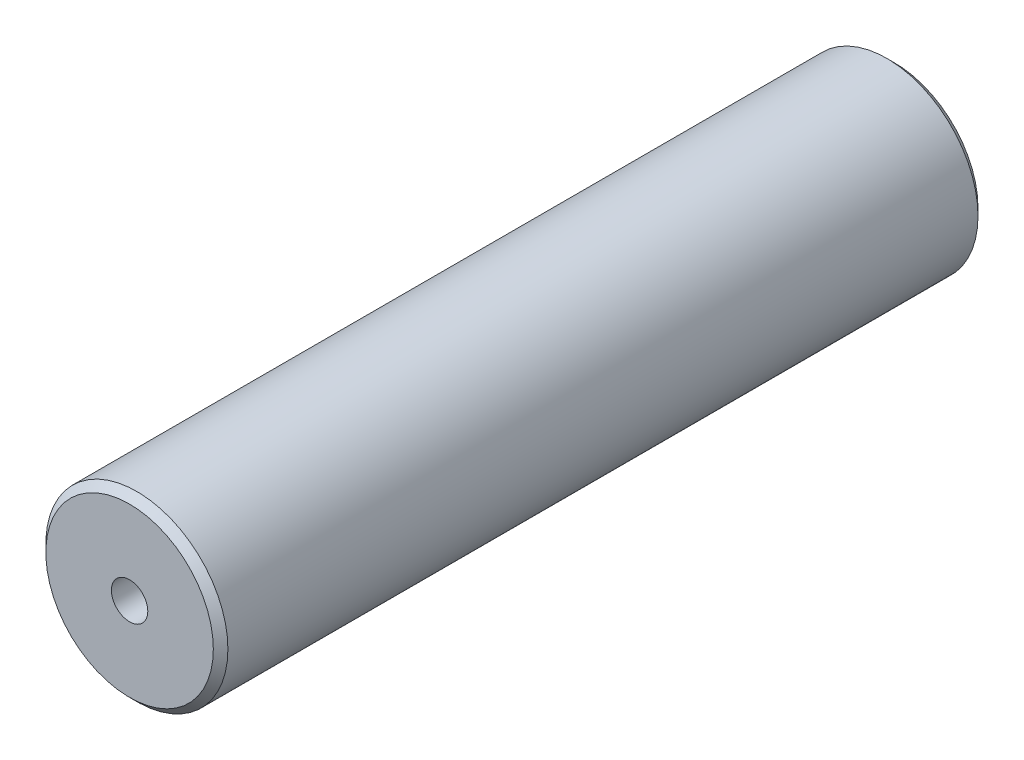
from build123d import *

# Parameters (mm, degrees)
SKETCH1_R           = 12.5
BOSS_EXTRUDE1_DEPTH = 52.5
CHAMFER1_SIZE       = 1


with BuildPart() as part:
    # Sketch1 → Boss-Extrude1 (new body, symmetric)
    with BuildSketch(Plane.XY):
        Circle(SKETCH1_R)
    extrude(amount=BOSS_EXTRUDE1_DEPTH, both=True)

    # Chamfer1
    chamfer1_edges = [part.edges().sort_by_distance(p)[0] for p in [
        (-12.5, 0, -52.5),
        (-12.5, 0, 52.5),
    ]]
    chamfer(chamfer1_edges, length=CHAMFER1_SIZE)

    # Sketch4 → Tap Drill for M6 Tap1 (revolve, cut)
    with BuildSketch(Plane(origin=(0, 0, 52.5), x_dir=(0, -1, 0), z_dir=(1, 0, 0))):
        Polygon((0, 0), (0, 14.502151548), (2.5, 13), (2.5, 0), align=None)
    tap_drill_for_m6_tap1 = revolve(axis=Axis((0, 0, 58.85), (0, 0, -1)), mode=Mode.SUBTRACT)

    # Mirror1: Tap Drill for M6 Tap1 across plane
    add(tap_drill_for_m6_tap1.mirror(Plane.XY), mode=Mode.SUBTRACT)


solid = part.part
